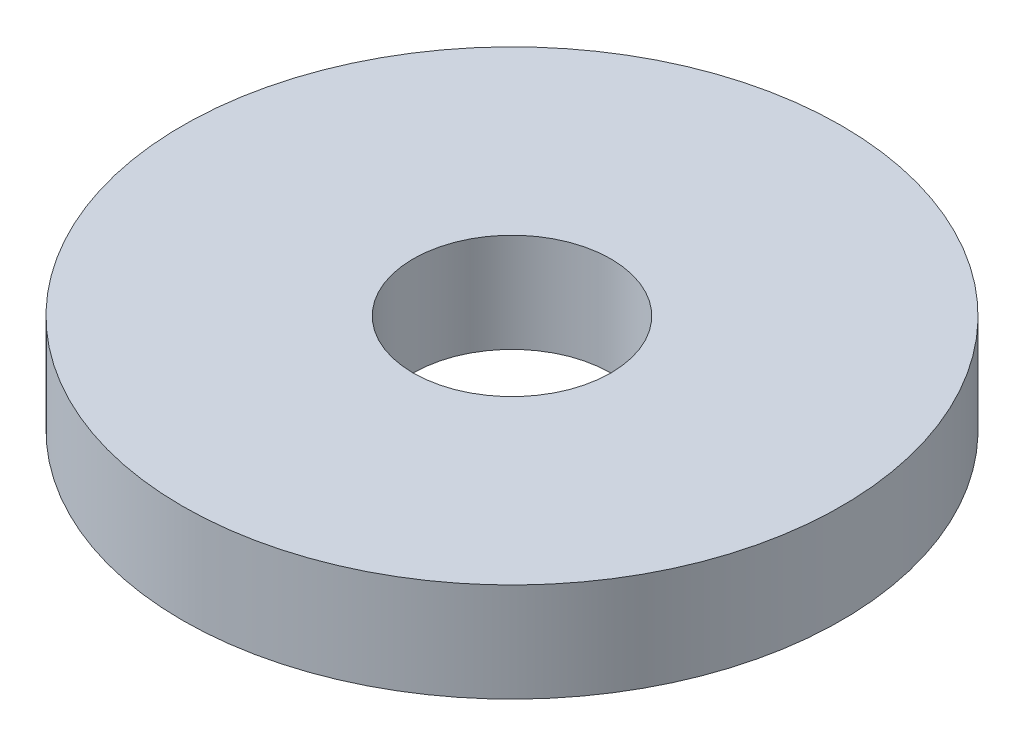
from build123d import *

# Parameters (mm, degrees)
SKETCH1_R           = 5
SKETCH1_R_2         = 1.5
BOSS_EXTRUDE1_DEPTH = 1.5


with BuildPart() as part:
    # Sketch1 → Boss-Extrude1 (new body)
    with BuildSketch(Plane(origin=(0, 0, 0), x_dir=(1, 0, 0), z_dir=(0, 1, 0))):
        Circle(SKETCH1_R)
        Circle(SKETCH1_R_2, mode=Mode.SUBTRACT)
    extrude(amount=BOSS_EXTRUDE1_DEPTH)


solid = part.part
